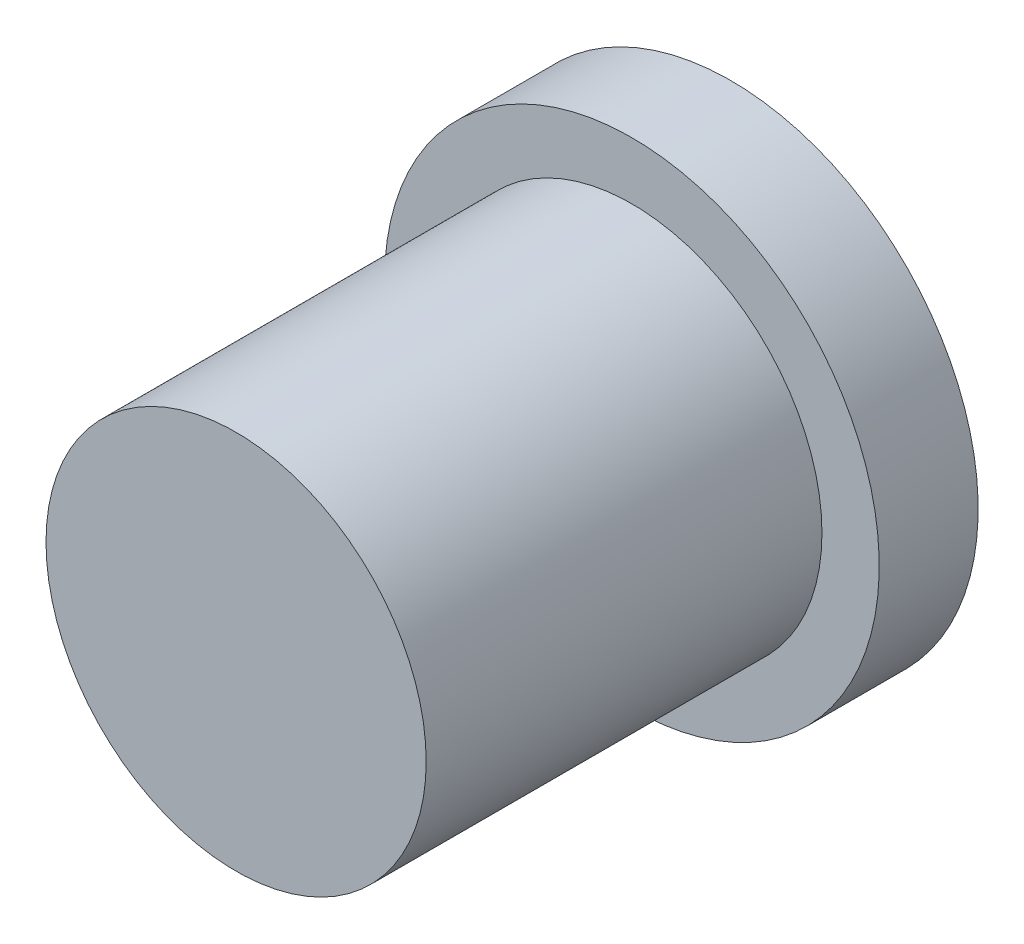
from build123d import *

# Parameters (mm, degrees)
SKETCH1_R           = 6.35
BOSS_EXTRUDE1_DEPTH = 12.7
SKETCH2_R           = 7.9375
BOSS_EXTRUDE2_DEPTH = 3.175
MOVE_FACE1_BY       = 0.25


with BuildPart() as part:
    # Sketch1 → Boss-Extrude1 (new body)
    with BuildSketch(Plane.XY):
        Circle(SKETCH1_R)
    extrude(amount=BOSS_EXTRUDE1_DEPTH)

    # Sketch2 → Boss-Extrude2 (add)
    with BuildSketch(Plane(origin=(0, 0, 0), x_dir=(-1, 0, 0), z_dir=(0, 0, -1))):
        Circle(SKETCH2_R)
    extrude(amount=BOSS_EXTRUDE2_DEPTH)

    # Move Face1: a curved face moved inward by 0.25
    add(Solid.thicken(part.faces().sort_by_distance((-6.35, 0, 6.35))[0], -MOVE_FACE1_BY), mode=Mode.SUBTRACT)


solid = part.part
